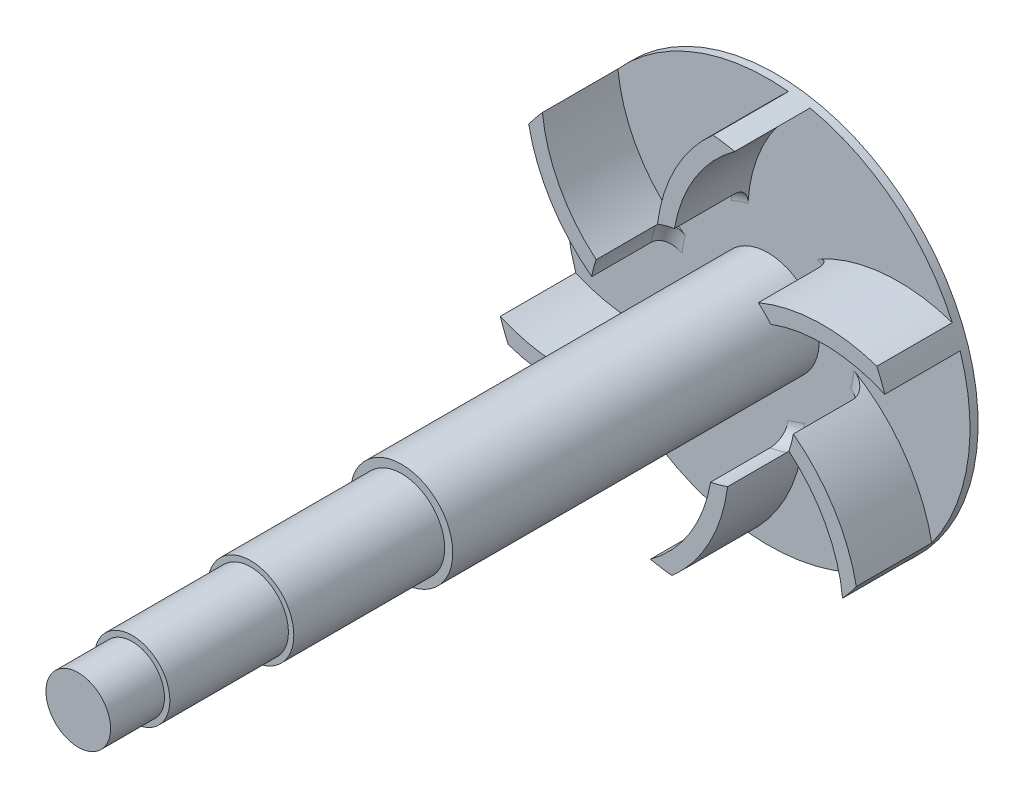
from build123d import *

# Parameters (mm, degrees)
SKETCH1_R           = 9.5
BOSS_EXTRUDE1_DEPTH = 68
SKETCH2_R           = 8
BOSS_EXTRUDE2_DEPTH = 28
SKETCH3_R           = 7
BOSS_EXTRUDE3_DEPTH = 22
SKETCH4_R           = 6
BOSS_EXTRUDE4_DEPTH = 10
SKETCH5_R           = 37.5
BOSS_EXTRUDE5_DEPTH = 1.5
SKETCH6_R           = 12.5
SKETCH6_R_2         = 7
BOSS_EXTRUDE6_DEPTH = 17.5
FILLET1_R           = 6
BOSS_EXTRUDE7_DEPTH = 14
FILLET2_R           = 3


with BuildPart() as part:
    # Sketch1 → Boss-Extrude1 (new body)
    with BuildSketch(Plane.XY):
        Circle(SKETCH1_R)
    extrude(amount=BOSS_EXTRUDE1_DEPTH)

    # Sketch2 → Boss-Extrude2 (add)
    with BuildSketch(Plane.XY.offset(68)):
        Circle(SKETCH2_R)
    extrude(amount=BOSS_EXTRUDE2_DEPTH)

    # Sketch3 → Boss-Extrude3 (add)
    with BuildSketch(Plane.XY.offset(96)):
        Circle(SKETCH3_R)
    extrude(amount=BOSS_EXTRUDE3_DEPTH)

    # Sketch4 → Boss-Extrude4 (add)
    with BuildSketch(Plane.XY.offset(118)):
        Circle(SKETCH4_R)
    extrude(amount=BOSS_EXTRUDE4_DEPTH)

    # Sketch5 → Boss-Extrude5 (add)
    with BuildSketch(Plane(origin=(0, 0, 0), x_dir=(-1, 0, 0), z_dir=(0, 0, -1))):
        Circle(SKETCH5_R)
    extrude(amount=BOSS_EXTRUDE5_DEPTH)

    # Sketch6 → Boss-Extrude6 (add)
    with BuildSketch(Plane(origin=(0, 0, -1.5), x_dir=(-1, 0, 0), z_dir=(0, 0, -1))):
        Circle(SKETCH6_R)
        Circle(SKETCH6_R_2, mode=Mode.SUBTRACT)
    extrude(amount=BOSS_EXTRUDE6_DEPTH)

    # Fillet1
    fillet1_edges = [part.edges().sort_by_distance(p)[0] for p in [
        (12.5, 0, -1.5),
    ]]
    fillet(fillet1_edges, radius=FILLET1_R)

    # Sketch8 → Boss-Extrude7 (add)
    with BuildSketch(Plane.XY):
        with BuildLine():
            ThreePointArc((-14.519262929, -12.255243939), (-13.410586975, -13.459426325), (-12.202382266, -14.563717487))
            ThreePointArc((-12.202382266, -14.563717487), (-23.134563913, -16.979972169), (-34.212072677, -15.355262394))
            ThreePointArc((-34.212072677, -15.355262394), (-34.993730727, -13.479199154), (-35.672601083, -11.563543228))
            ThreePointArc((-35.672601083, -11.563543228), (-25.163804407, -13.985042516), (-14.519262929, -12.255243939))
        make_face()
        with BuildLine():
            ThreePointArc((7.821978348, 36.675150371), (0.470500112, 28.78501513), (-3.353721116, 18.70167251))
            ThreePointArc((-3.353721116, 18.70167251), (-4.95091163, 18.343622162), (-6.511358184, 17.849431772))
            ThreePointArc((-6.511358184, 17.849431772), (-3.137805297, 28.525106139), (3.807989024, 37.306155251))
            ThreePointArc((3.807989024, 37.306155251), (5.823536473, 37.045059359), (7.821978348, 36.675150371))
        make_face()
        with BuildLine():
            ThreePointArc((-27.850622735, 25.111607143), (-24.693304295, 14.799972614), (-17.872984045, 6.446428571))
            ThreePointArc((-17.872984045, 6.446428571), (-18.361498605, 4.884195838), (-18.71374045, 3.285714286))
            ThreePointArc((-18.71374045, 3.285714286), (-26.27236921, 11.54513397), (-30.404083653, 21.950892857))
            ThreePointArc((-30.404083653, 21.950892857), (-29.170194253, 23.565860206), (-27.850622735, 25.111607143))
        make_face()
        with BuildLine():
            ThreePointArc((35.672601083, 11.563543228), (25.163804407, 13.985042516), (14.519262929, 12.255243939))
            ThreePointArc((14.519262929, 12.255243939), (13.410586975, 13.459426325), (12.202382266, 14.563717487))
            ThreePointArc((12.202382266, 14.563717487), (23.134563913, 16.979972169), (34.212072677, 15.355262394))
            ThreePointArc((34.212072677, 15.355262394), (34.993730727, 13.479199154), (35.672601083, 11.563543228))
        make_face()
        with BuildLine():
            ThreePointArc((27.850622735, -25.111607143), (24.693304295, -14.799972614), (17.872984045, -6.446428571))
            ThreePointArc((17.872984045, -6.446428571), (18.361498605, -4.884195838), (18.71374045, -3.285714286))
            ThreePointArc((18.71374045, -3.285714286), (26.27236921, -11.54513397), (30.404083653, -21.950892857))
            ThreePointArc((30.404083653, -21.950892857), (29.170194253, -23.565860206), (27.850622735, -25.111607143))
        make_face()
        with BuildLine():
            ThreePointArc((-7.821978348, -36.675150371), (-0.470500112, -28.78501513), (3.353721116, -18.70167251))
            ThreePointArc((3.353721116, -18.70167251), (4.95091163, -18.343622162), (6.511358184, -17.849431772))
            ThreePointArc((6.511358184, -17.849431772), (3.137805297, -28.525106139), (-3.807989024, -37.306155251))
            ThreePointArc((-3.807989024, -37.306155251), (-5.823536473, -37.045059359), (-7.821978348, -36.675150371))
        make_face()
    extrude(amount=BOSS_EXTRUDE7_DEPTH)

    # Fillet2
    fillet2_edges = [part.edges().sort_by_distance(p)[0] for p in [
        (-18.361498605, 4.884195838, 0),
        (-4.95091163, 18.343622162, 0),
        (13.410586975, 13.459426325, 0),
        (18.361498605, -4.884195838, 0),
        (4.95091163, -18.343622162, 0),
        (-13.410586975, -13.459426325, 0),
    ]]
    fillet(fillet2_edges, radius=FILLET2_R)


solid = part.part
